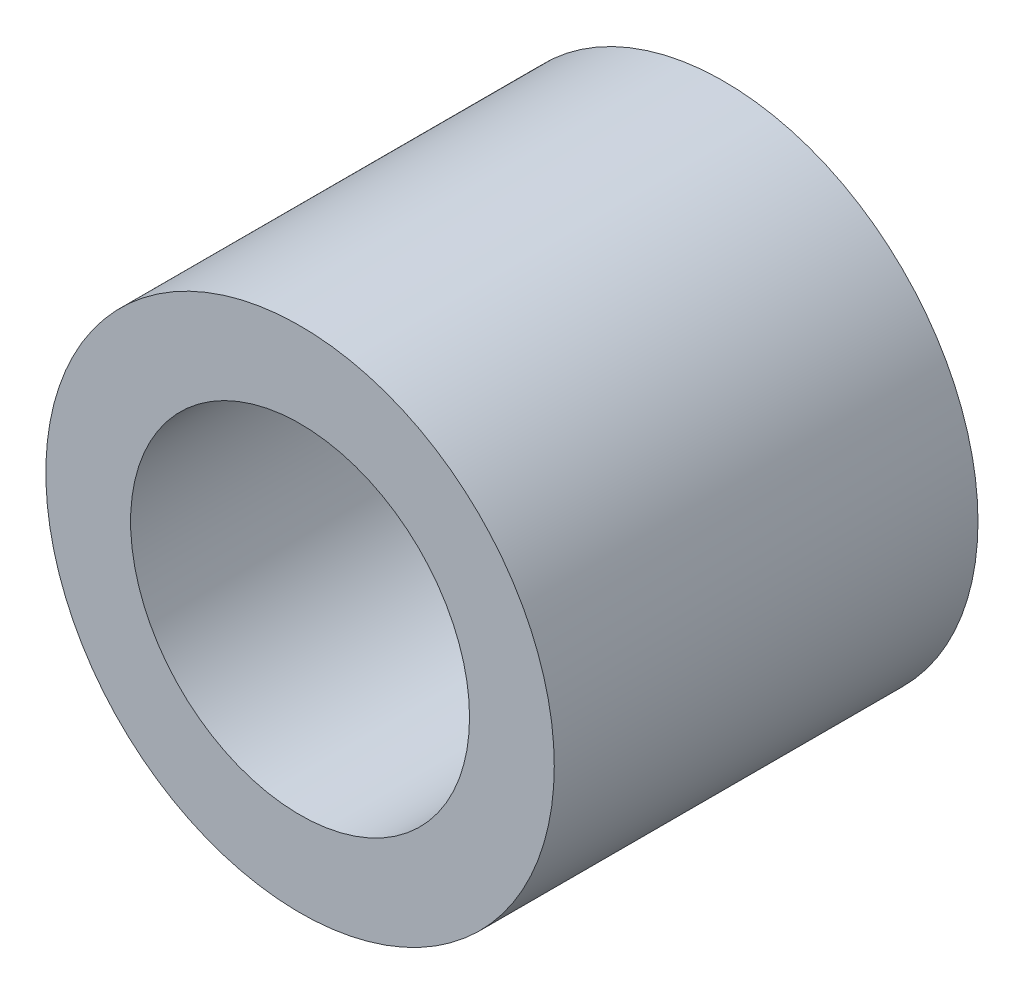
from build123d import *

# Parameters (mm, degrees)
ESQUISSE1_R        = 6
ESQUISSE1_R_2      = 4
BOSS_EXTRU_1_DEPTH = 10


with BuildPart() as part:
    # Esquisse1 → Boss.-Extru.1 (new body)
    with BuildSketch(Plane.XY):
        with Locations((14.491448417, -8.848191188)):
            Circle(ESQUISSE1_R)
        with Locations((14.491448417, -8.848191188)):
            Circle(ESQUISSE1_R_2, mode=Mode.SUBTRACT)
    extrude(amount=BOSS_EXTRU_1_DEPTH)


solid = part.part
